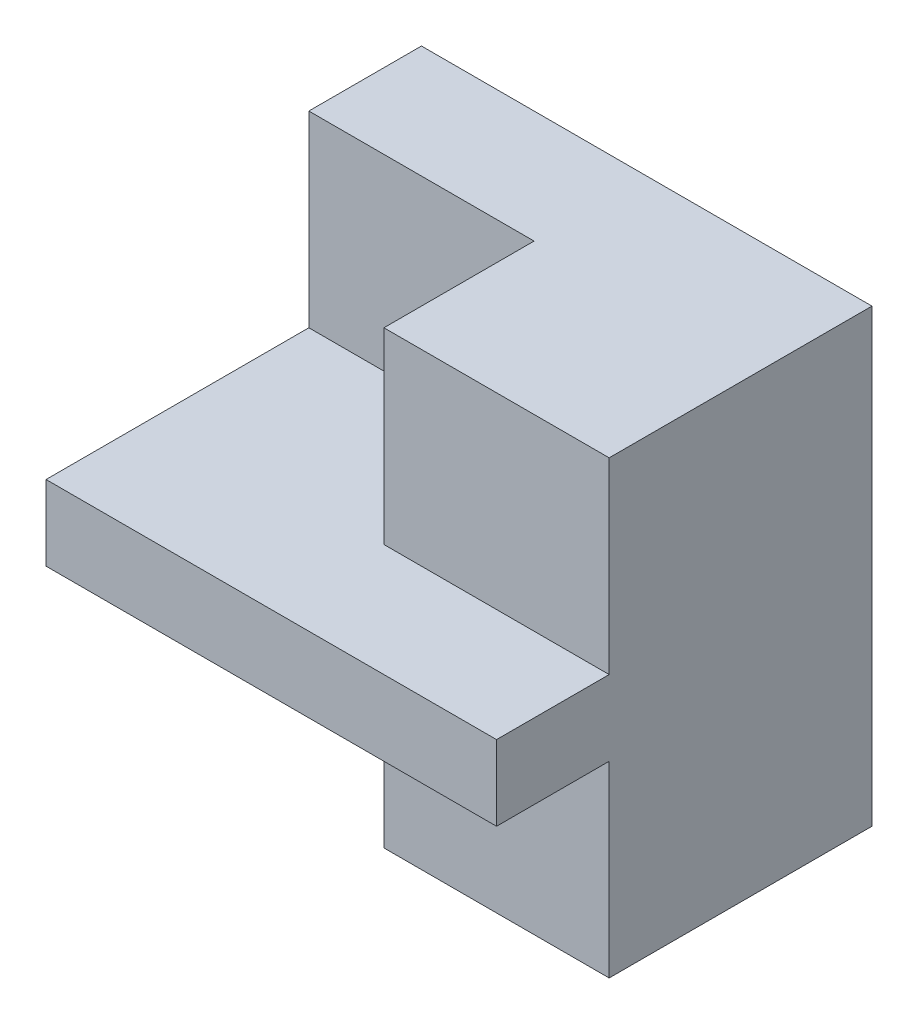
from build123d import *

# Parameters (mm, degrees)
SKETCH1_W           = 6
SKETCH1_H           = 5
BOSS_EXTRUDE1_DEPTH = 6
CUT_EXTRUDE1_DEPTH  = 2.5
CUT_EXTRUDE2_DEPTH  = 2.5


with BuildPart() as part:
    # Sketch1 → Boss-Extrude1 (new body)
    with BuildSketch(Plane(origin=(0, 0, 0), x_dir=(1, 0, 0), z_dir=(0, 1, 0))):
        Rectangle(SKETCH1_W, SKETCH1_H)
    extrude(amount=BOSS_EXTRUDE1_DEPTH)

    # Sketch2 → Cut-Extrude1 (cut)
    with BuildSketch(Plane(origin=(0, 6, 0), x_dir=(1, 0, 0), z_dir=(0, 1, 0))):
        Polygon((3, -1), (0, -1), (0, 1), (-3, 1), (-3, -2.5), (3, -2.5), align=None)
    extrude(amount=-CUT_EXTRUDE1_DEPTH, mode=Mode.SUBTRACT)

    # Sketch3 → Cut-Extrude2 (cut)
    with BuildSketch(Plane.XZ):
        Polygon((3, 1), (0, 1), (0, -1), (-3, -1), (-3, 2.5), (3, 2.5), align=None)
    extrude(amount=-CUT_EXTRUDE2_DEPTH, mode=Mode.SUBTRACT)


solid = part.part
